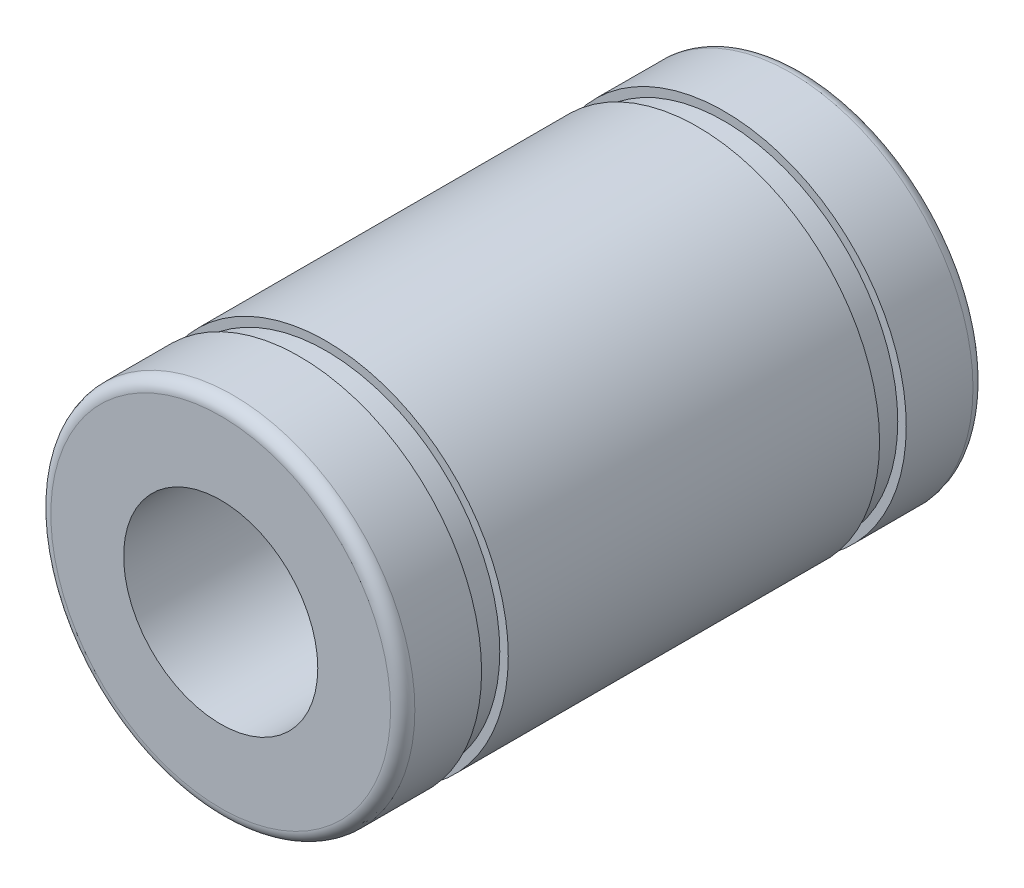
from build123d import *

# Parameters (mm, degrees)
FILLET2_R = 0.5
FILLET3_R = 0.5


with BuildPart() as part:
    # Sketch1 → Revolve1 (revolve)
    with BuildSketch(Plane(origin=(0, 0, 0), x_dir=(0, 0, -1), z_dir=(1, 0, 0))):
        Polygon((-12, -7.5), (-8.75, -7.5), (-8.75, -7.15), (-7.65, -7.15), (-7.65, -7.5), (0, -7.5), (0, -4), (-12, -4), align=None)
    revolve1 = revolve(axis=Axis((0, 0, 1000), (0, 0, -1)))

    # Fillet2
    fillet2_edges = [part.edges().sort_by_distance(p)[0] for p in [
        (0, 7.5, 12),
    ]]
    fillet(fillet2_edges, radius=FILLET2_R)

    # Mirror2: Revolve1 across plane
    add(revolve1.mirror(Plane(origin=(0, -4, 0), x_dir=(1, 0, 0), z_dir=(0, 0, -1))))

    # Fillet3
    fillet3_edges = [part.edges().sort_by_distance(p)[0] for p in [
        (0, 7.5, -12),
    ]]
    fillet(fillet3_edges, radius=FILLET3_R)


solid = part.part
